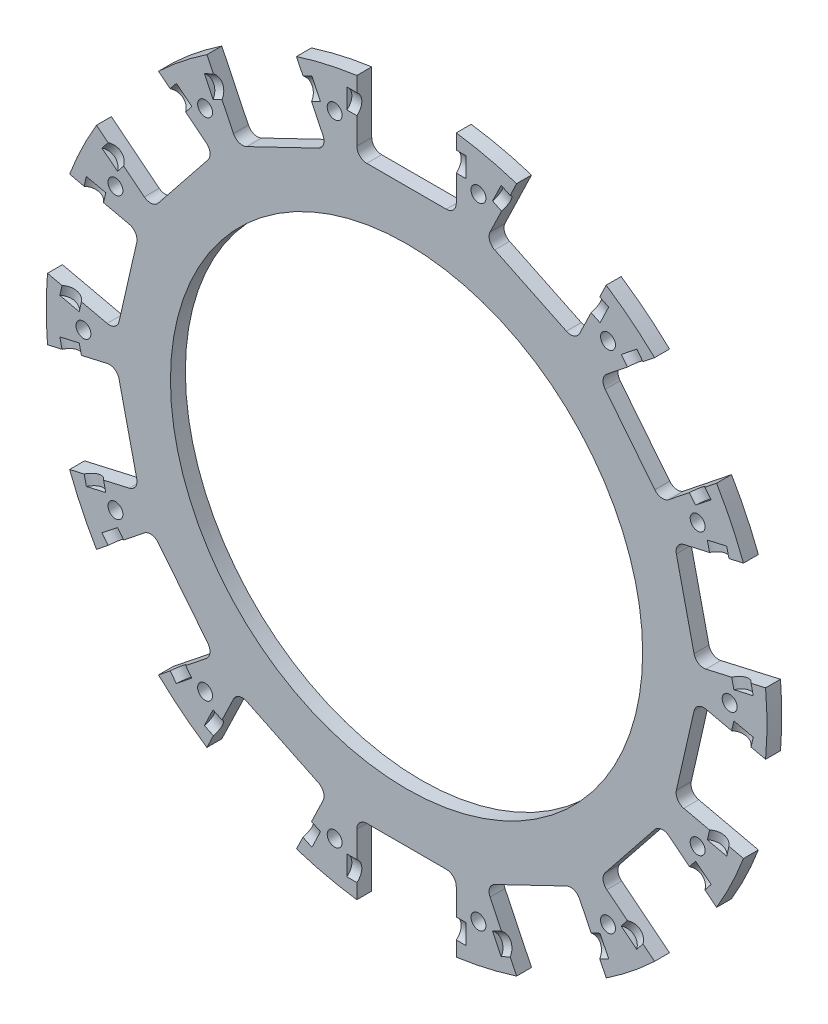
from build123d import *

# Parameters (mm, degrees)
SKETCH_1_R               = 47.5
EXTRUDE_1_DEPTH          = 3
SKETCH_2_R               = 11
CUT_EXTRUDE_1_DEPTH      = 4
PATTERN_CIRCULAR_1_COUNT = 6
SKETCH_3_R               = 2.55
CUT_EXTRUDE_2_DEPTH      = 4
PATTERN_CIRCULAR_2_COUNT = 6
SKETCH_4_R               = 12.9
CUT_EXTRUDE_3_DEPTH      = 4
SKETCH_5_R               = 72.5
SKETCH_5_R_2             = 47.5
EXTRUDE_2_DEPTH          = 3
SKETCH_6_W               = 20
SKETCH_6_H               = 30
CUT_EXTRUDE_4_DEPTH      = 4
PATTERN_CIRCULAR_3_COUNT = 14
SKETCH_7_R               = 1.5
CUT_EXTRUDE_5_DEPTH      = 4
PATTERN_CIRCULAR_4_COUNT = 14
SKETCH_8_R               = 47.5
CUT_EXTRUDE_6_DEPTH      = 4
SKETCH_9_R               = 2.5
CUT_EXTRUDE_7_DEPTH      = 2
SKETCH_10_R              = 2.5
CUT_EXTRUDE_8_DEPTH      = 2
PATTERN_CIRCULAR_5_COUNT = 14
FILLET_1_R               = 2


with BuildPart() as part:
    # 草图1 → 凸台-拉伸1 (new body)
    with BuildSketch(Plane.XY):
        Circle(SKETCH_1_R)
    extrude(amount=EXTRUDE_1_DEPTH)

    # 草图2 → 切除-拉伸1 (cut, through all)
    with BuildSketch(Plane.XY.offset(3)):
        with Locations((0, 35)):
            Circle(SKETCH_2_R)
    cut_extrude_1 = extrude(amount=-CUT_EXTRUDE_1_DEPTH, mode=Mode.SUBTRACT)

    # 阵列(圆周)1: 切除-拉伸1 ×6 about axis
    pattern_circular_1_axis = Axis((0, 0, 0), (0, 0, 1))
    for i in range(1, PATTERN_CIRCULAR_1_COUNT):
        add(cut_extrude_1.rotate(pattern_circular_1_axis, i * 360 / PATTERN_CIRCULAR_1_COUNT), mode=Mode.SUBTRACT)

    # 草图3 → 切除-拉伸2 (cut, through all)
    with BuildSketch(Plane.XY.offset(3)):
        with Locations((11.25, 19.485571585)):
            Circle(SKETCH_3_R)
    cut_extrude_2 = extrude(amount=-CUT_EXTRUDE_2_DEPTH, mode=Mode.SUBTRACT)

    # 阵列(圆周)2: 切除-拉伸2 ×6 about axis
    pattern_circular_2_axis = Axis((0, 0, 0), (0, 0, 1))
    for i in range(1, PATTERN_CIRCULAR_2_COUNT):
        add(cut_extrude_2.rotate(pattern_circular_2_axis, i * 360 / PATTERN_CIRCULAR_2_COUNT), mode=Mode.SUBTRACT)

    # 草图4 → 切除-拉伸3 (cut, through all)
    with BuildSketch(Plane.XY.offset(3)):
        Circle(SKETCH_4_R)
    extrude(amount=-CUT_EXTRUDE_3_DEPTH, mode=Mode.SUBTRACT)

    # 草图5 → 凸台-拉伸2 (add)
    with BuildSketch(Plane.XY.offset(3)):
        Circle(SKETCH_5_R)
        Circle(SKETCH_5_R_2, mode=Mode.SUBTRACT)
    extrude(amount=-EXTRUDE_2_DEPTH)

    # 草图6 → 切除-拉伸4 (cut, through all)
    with BuildSketch(Plane(origin=(0, 0, 0), x_dir=(-1, 0, 0), z_dir=(0, 0, -1))):
        with Locations((0, 72.5)):
            Rectangle(SKETCH_6_W, SKETCH_6_H)
    cut_extrude_4 = extrude(amount=-CUT_EXTRUDE_4_DEPTH, mode=Mode.SUBTRACT)

    # 阵列(圆周)3: 切除-拉伸4 ×14 about axis
    pattern_circular_3_axis = Axis((0, 0, 0), (0, 0, 1))
    for i in range(1, PATTERN_CIRCULAR_3_COUNT):
        add(cut_extrude_4.rotate(pattern_circular_3_axis, i * 360 / PATTERN_CIRCULAR_3_COUNT), mode=Mode.SUBTRACT)

    # 草图7 → 切除-拉伸5 (cut, through all)
    with BuildSketch(Plane.XY.offset(3)):
        with Locations((-14.463860707, 63.370314292)):
            Circle(SKETCH_7_R)
    cut_extrude_5 = extrude(amount=-CUT_EXTRUDE_5_DEPTH, mode=Mode.SUBTRACT)

    # 阵列(圆周)4: 切除-拉伸5 ×14 about axis
    pattern_circular_4_axis = Axis((0, 0, 0), (0, 0, 1))
    for i in range(1, PATTERN_CIRCULAR_4_COUNT):
        add(cut_extrude_5.rotate(pattern_circular_4_axis, i * 360 / PATTERN_CIRCULAR_4_COUNT), mode=Mode.SUBTRACT)

    # 草图8 → 切除-拉伸6 (cut, through all)
    with BuildSketch(Plane.XY.offset(3)):
        Circle(SKETCH_8_R)
    extrude(amount=-CUT_EXTRUDE_6_DEPTH, mode=Mode.SUBTRACT)

    # 草图9 → 切除-拉伸7 (cut)
    with BuildSketch(Plane(origin=(-6.234898019, 7.818314825, 0), x_dir=(0.781831482, 0.623489802, 0), z_dir=(0.623489802, -0.781831482, 0))):
        with Locations((66.807033082, 4.5)):
            Circle(SKETCH_9_R)
    cut_extrude_7 = extrude(amount=-CUT_EXTRUDE_7_DEPTH, mode=Mode.SUBTRACT)

    # 草图10 → 切除-拉伸8 (cut)
    with BuildSketch(Plane(origin=(9.009688679, -4.338837391, 0), x_dir=(0, 0, 1), z_dir=(-0.900968868, 0.433883739, 0))):
        with Locations((4.5, 66.807033082)):
            Circle(SKETCH_10_R)
    cut_extrude_8 = extrude(amount=-CUT_EXTRUDE_8_DEPTH, mode=Mode.SUBTRACT)

    # 阵列(圆周)5: 切除-拉伸7, 切除-拉伸8 ×14 about axis
    pattern_circular_5_axis = Axis((0, 0, 0), (0, 0, 1))
    for i in range(1, PATTERN_CIRCULAR_5_COUNT):
        add(cut_extrude_7.rotate(pattern_circular_5_axis, i * 360 / PATTERN_CIRCULAR_5_COUNT), mode=Mode.SUBTRACT)
        add(cut_extrude_8.rotate(pattern_circular_5_axis, i * 360 / PATTERN_CIRCULAR_5_COUNT), mode=Mode.SUBTRACT)

    # 圆角1
    fillet_1_edges = [part.edges().sort_by_distance(p)[0] for p in [
        (-51.19020826, 28.032348782, 1.5),
        (-38.720412223, 43.668978432, 1.5),
        (-58.28356429, 3.045674581, 1.5),
        (-53.833145611, 22.544232824, 1.5),
        (-53.833145611, -22.544232824, 1.5),
        (-58.28356429, -3.045674581, 1.5),
        (-38.720412223, -43.668978432, 1.5),
        (-51.19020826, -28.032348782, 1.5),
        (-15.93862632, -56.144547296, 1.5),
        (-33.958003678, -47.466872513, 1.5),
        (10, -57.5, 1.5),
        (-10, -57.5, 1.5),
        (33.958003678, -47.466872513, 1.5),
        (15.93862632, -56.144547296, 1.5),
        (51.19020826, -28.032348782, 1.5),
        (38.720412223, -43.668978432, 1.5),
        (58.28356429, -3.045674581, 1.5),
        (53.833145611, -22.544232824, 1.5),
        (53.833145611, 22.544232824, 1.5),
        (58.28356429, 3.045674581, 1.5),
        (38.720412223, 43.668978432, 1.5),
        (51.19020826, 28.032348782, 1.5),
        (15.93862632, 56.144547296, 1.5),
        (33.958003678, 47.466872513, 1.5),
        (-10, 57.5, 1.5),
        (10, 57.5, 1.5),
        (-33.958003678, 47.466872513, 1.5),
        (-15.93862632, 56.144547296, 1.5),
    ]]
    fillet(fillet_1_edges, radius=FILLET_1_R)


solid = part.part
